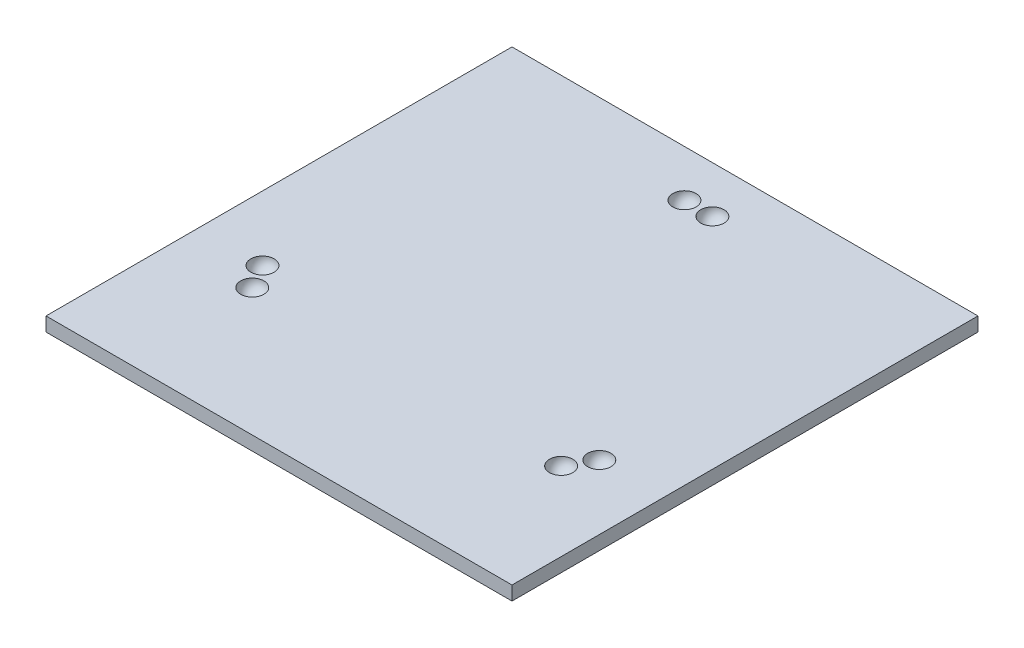
from build123d import *

# Parameters (mm, degrees)
SKETCH1_W           = 200
SKETCH1_H           = 200
BOSS_EXTRUDE1_DEPTH = 6


with BuildPart() as part:
    # Sketch1 → Boss-Extrude1 (new body)
    with BuildSketch(Plane(origin=(0, 0, 0), x_dir=(1, 0, 0), z_dir=(0, 1, 0))):
        Rectangle(SKETCH1_W, SKETCH1_H)
    extrude(amount=BOSS_EXTRUDE1_DEPTH)

    # Sketch2 → Cut-Revolve1 (revolve, cut)
    with BuildSketch(Plane.XY.offset(-80)):
        with BuildLine():
            Line((-11, 6), (-6, 6))
            Line((-6, 6), (-6, 1))
            ThreePointArc((-6, 1), (-9.535533906, 2.464466094), (-11, 6))
        make_face()
    cut_revolve1 = revolve(axis=Axis((-6, 6, -80), (0, -1, 0)), mode=Mode.SUBTRACT)

    # Sketch4 → Cut-Revolve2 (revolve, cut)
    with BuildSketch(Plane(origin=(-69.282032303, 0, 40), x_dir=(0, -1, 0), z_dir=(-0.8660254037844398, 0, 0.499999999999998))):
        with BuildLine():
            Line((-1, 6), (-6, 6))
            Line((-6, 6), (-6, 11))
            ThreePointArc((-6, 11), (-2.464466094, 9.535533906), (-1, 6))
        make_face()
    cut_revolve2 = revolve(axis=Axis((-66.282032303, 1, 45.196152423), (0, 1, 0)), mode=Mode.SUBTRACT)

    # Mirror1: Cut-Revolve2 across plane
    add(cut_revolve2.mirror(Plane(origin=(0, 0, 0), x_dir=(-0.8660254037844398, 0, 0.499999999999998), z_dir=(-0.499999999999998, 0, -0.8660254037844398))), mode=Mode.SUBTRACT)

    # Mirror2: Cut-Revolve1 across plane
    add(cut_revolve1.mirror(Plane(origin=(0, 0, 0), x_dir=(0, 0, 1), z_dir=(1, 0, 0))), mode=Mode.SUBTRACT)

    # Mirror2 copy 1 sketch → Mirror2 copy 1 (revolve, cut)
    with BuildSketch(Plane(origin=(69.282032303, 0, 40), x_dir=(0, -1, 0), z_dir=(0.8660254037844398, 0, 0.499999999999998))):
        with BuildLine():
            Line((-1, 6), (-6, 6))
            Line((-6, 6), (-6, 11))
            ThreePointArc((-6, 11), (-2.464466094, 9.535533906), (-1, 6))
        make_face()
    revolve(axis=Axis((72.282032303, 1, 34.803847577), (0, 1, 0)), mode=Mode.SUBTRACT)

    # Mirror2 copy 2 sketch → Mirror2 copy 2 (revolve, cut)
    with BuildSketch(Plane(origin=(69.282032303, 0, 40), x_dir=(0, -1, 0), z_dir=(0.8660254037844398, 0, 0.499999999999998))):
        with BuildLine():
            Line((-1, -6), (-6, -6))
            Line((-6, -6), (-6, -11))
            ThreePointArc((-6, -11), (-2.464466094, -9.535533906), (-1, -6))
        make_face()
    revolve(axis=Axis((66.282032303, 1, 45.196152423), (0, -1, 0)), mode=Mode.SUBTRACT)


solid = part.part
